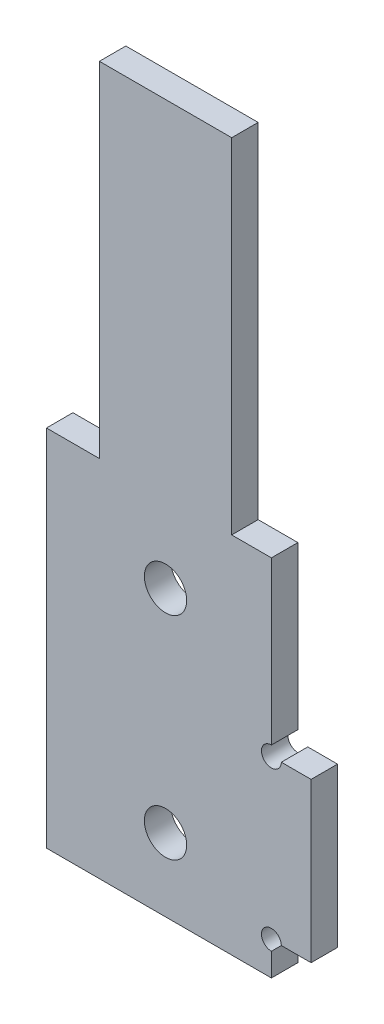
from build123d import *

# Parameters (mm, degrees)
EXTRUDE_1_DEPTH     = 2
SKETCH_2_R          = 1.6
CUT_EXTRUDE_1_DEPTH = 3
SKETCH_3_W          = 3
SKETCH_3_H          = 24
SKETCH_3_W_2        = 4
CUT_EXTRUDE_2_DEPTH = 3
SKETCH_4_W          = 10
SKETCH_4_H          = 2
EXTRUDE_2_DEPTH     = 2
SKETCH_5_R          = 0.75
CUT_EXTRUDE_3_DEPTH = 3


with BuildPart() as part:
    # 草图1 → 凸台-拉伸1 (new body)
    with BuildSketch(Plane.XY):
        Polygon((0, 0), (17, 0), (17, 2.5), (20, 2.5), (20, 14.5), (17, 14.5), (17, 51.5), (0, 51.5), align=None)
    extrude(amount=EXTRUDE_1_DEPTH)

    # 草图2 → 切除-拉伸1 (cut, through all)
    with BuildSketch(Plane.XY.offset(2)):
        with Locations((9, 5.5)):
            Circle(SKETCH_2_R)
        with Locations((9, 21.5)):
            Circle(SKETCH_2_R)
    extrude(amount=-CUT_EXTRUDE_1_DEPTH, mode=Mode.SUBTRACT)

    # 草图3 → 切除-拉伸2 (cut, through all)
    with BuildSketch(Plane.XY.offset(2)):
        with Locations((15.5, 39.5)):
            Rectangle(SKETCH_3_W, SKETCH_3_H)
        with Locations((2, 39.5)):
            Rectangle(SKETCH_3_W_2, SKETCH_3_H)
    extrude(amount=-CUT_EXTRUDE_2_DEPTH, mode=Mode.SUBTRACT)

    # 草图4 → 凸台-拉伸2 (add)
    with BuildSketch(Plane(origin=(0, 51.5, 0), x_dir=(1, 0, 0), z_dir=(0, 1, 0))):
        with Locations((9, -1)):
            Rectangle(SKETCH_4_W, SKETCH_4_H)
    extrude(amount=EXTRUDE_2_DEPTH)

    # 草图5 → 切除-拉伸3 (cut)
    with BuildSketch(Plane.XY.offset(2)):
        with Locations((17, 14.5)):
            Circle(SKETCH_5_R)
        with Locations((17, 2.5)):
            Circle(SKETCH_5_R)
    extrude(amount=-CUT_EXTRUDE_3_DEPTH, mode=Mode.SUBTRACT)


solid = part.part
